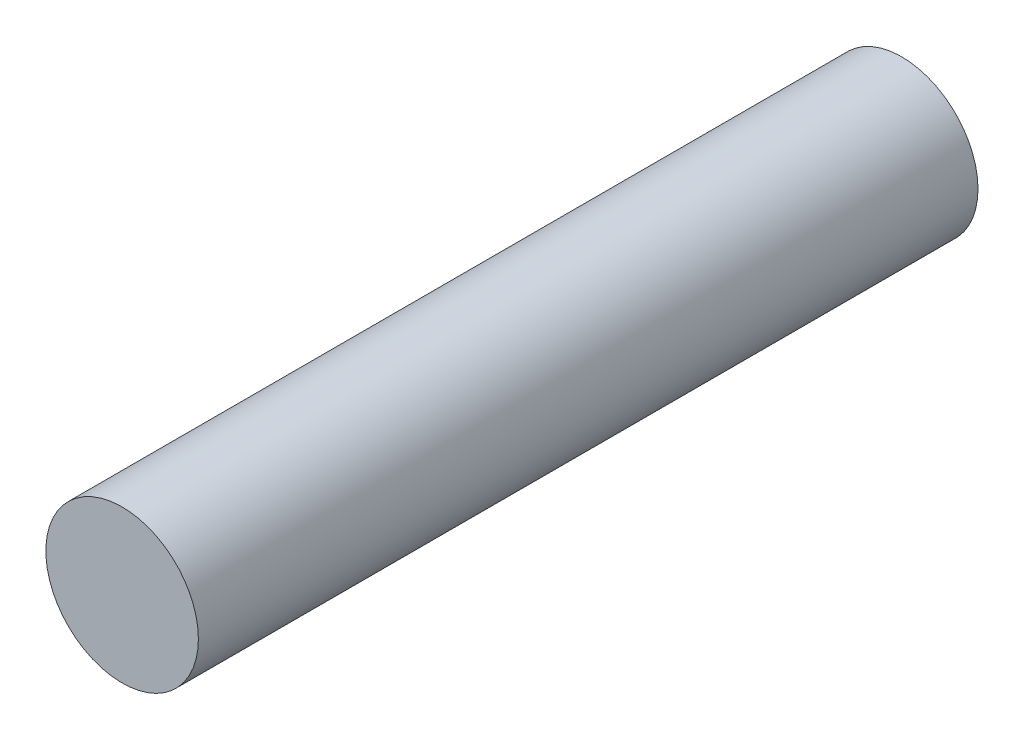
from build123d import *

# Parameters (mm, degrees)
SKETCH_1_R          = 2.25
EXTRUDE_2_DEPTH     = 23
SKETCH_7_W          = 2.35
SKETCH_7_H          = 2.35
CUT_EXTRUDE_3_DEPTH = 4.5


with BuildPart() as part:
    # 草图1 → 凸台-拉伸2 (new body)
    with BuildSketch(Plane.XY):
        Circle(SKETCH_1_R)
    extrude(amount=EXTRUDE_2_DEPTH)

    # 草图7 → 切除-拉伸3 (cut)
    with BuildSketch(Plane.XY):
        Rectangle(SKETCH_7_W, SKETCH_7_H)
    extrude(amount=CUT_EXTRUDE_3_DEPTH, mode=Mode.SUBTRACT)


solid = part.part
